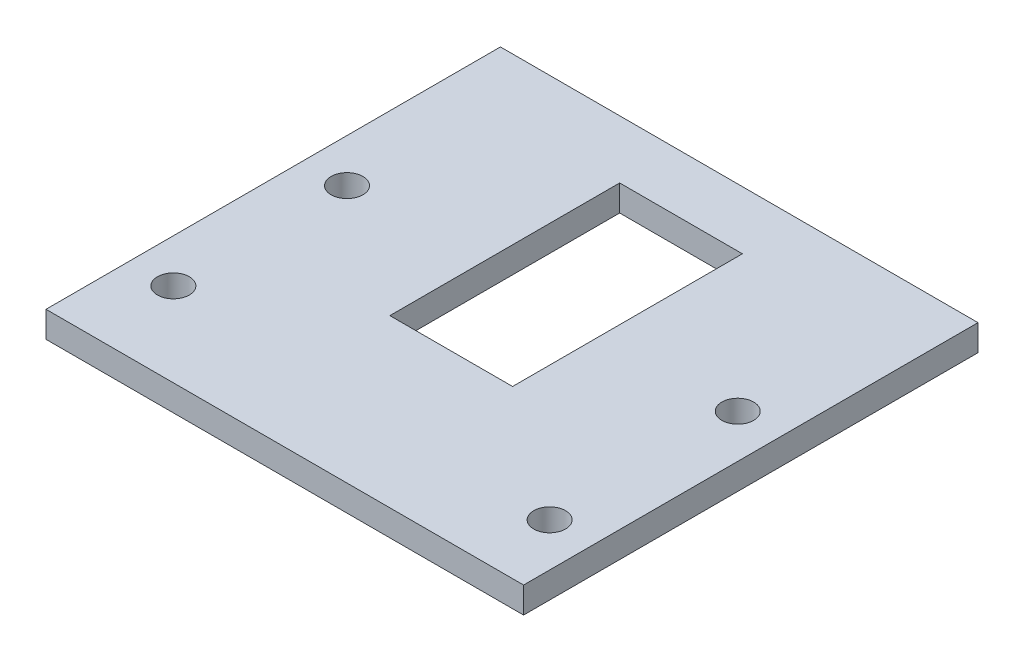
from build123d import *

# Parameters (mm, degrees)
SKETCH5_W      = 41.91
SKETCH5_H      = 39.878
SKETCH5_R      = 1.397
EXTRUDE3_DEPTH = 2.286
SKETCH6_W      = 10.7696
SKETCH6_H      = 20.1676
EXTRUDE4_DEPTH = 3.286


with BuildPart() as part:
    # Sketch5 → Extrude3 (new body)
    with BuildSketch(Plane(origin=(0, 0, 0), x_dir=(1, 0, 0), z_dir=(0, 1, 0))):
        with Locations((-20.955, -19.939)):
            Rectangle(SKETCH5_W, SKETCH5_H)
        with Locations((-38.1, -17.272)):
            Circle(SKETCH5_R, mode=Mode.SUBTRACT)
        with Locations((-38.1, -32.512)):
            Circle(SKETCH5_R, mode=Mode.SUBTRACT)
        with Locations((-3.81, -33.782)):
            Circle(SKETCH5_R, mode=Mode.SUBTRACT)
        with Locations((-3.81, -17.272)):
            Circle(SKETCH5_R, mode=Mode.SUBTRACT)
    extrude(amount=EXTRUDE3_DEPTH)

    # Sketch6 → Extrude4 (cut, through all)
    with BuildSketch(Plane(origin=(0, 2.286, 0), x_dir=(-1, 0, 0), z_dir=(0, 1, 0))):
        with Locations((20.955, 15.1892)):
            Rectangle(SKETCH6_W, SKETCH6_H)
    extrude(amount=-EXTRUDE4_DEPTH, mode=Mode.SUBTRACT)


solid = part.part
